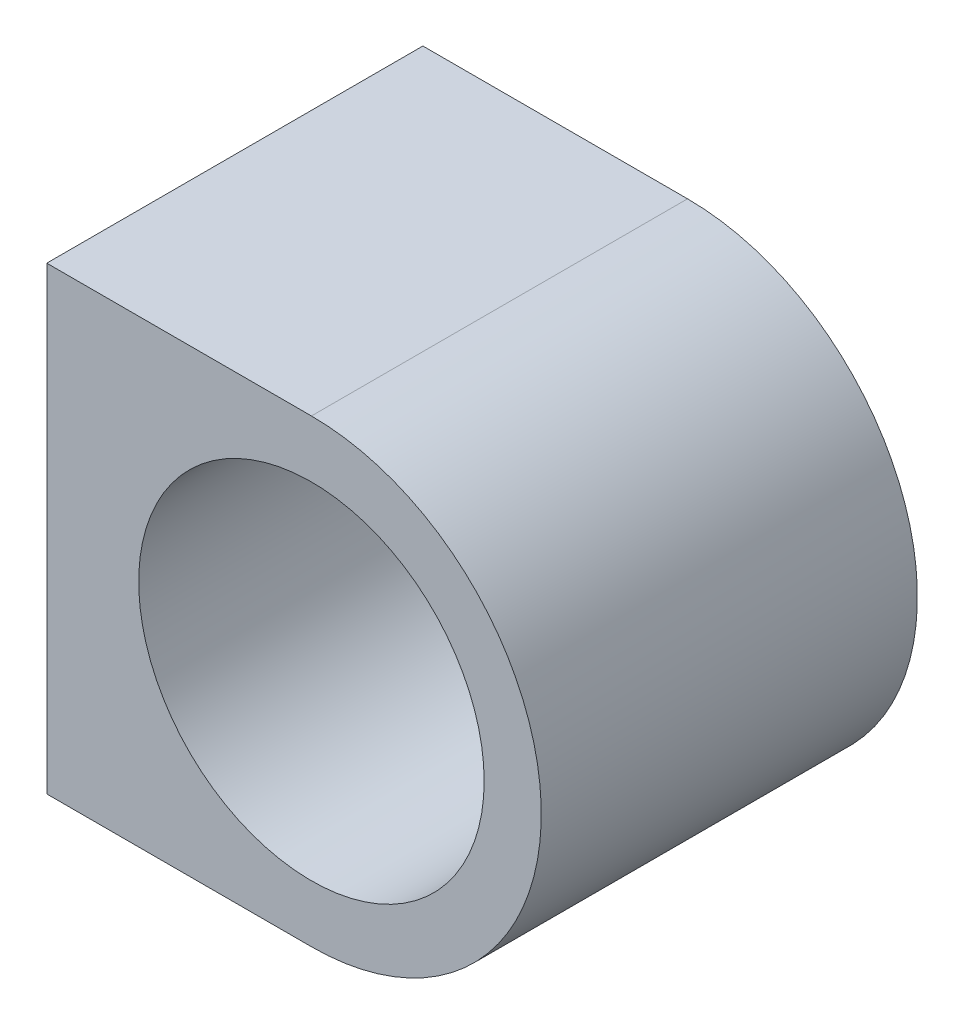
from build123d import *

# Parameters (mm, degrees)
SKETCH1_R                      = 6.2
BOSS_EXTRUDE1_DEPTH            = 13.5
F_2_7_2_7_DIAMETER_HOLE1_D     = 2.7
F_2_7_2_7_DIAMETER_HOLE1_DEPTH = 4
F_2_7_2_7_DIAMETER_HOLE1_TIP   = 0.811161836


with BuildPart() as part:
    # Sketch1 → Boss-Extrude1 (new body)
    with BuildSketch(Plane.XY):
        with BuildLine():
            Line((-9.5, 8.25), (-9.5, -8.25))
            Line((-9.5, -8.25), (0, -8.25))
            ThreePointArc((0, -8.25), (8.25, 0), (0, 8.25))
            Line((0, 8.25), (-9.5, 8.25))
        make_face()
        Circle(SKETCH1_R, mode=Mode.SUBTRACT)
    extrude(amount=BOSS_EXTRUDE1_DEPTH)

    # Ø2.7 (2.7) Diameter Hole1
    with Locations(Plane.ZY.offset(9.5)):
        with Locations((2.5, -5), (2.5, 5), (11, 5), (11, -5)):
            Hole(F_2_7_2_7_DIAMETER_HOLE1_D / 2, depth=F_2_7_2_7_DIAMETER_HOLE1_DEPTH)
            with Locations((0, 0, -(F_2_7_2_7_DIAMETER_HOLE1_DEPTH + F_2_7_2_7_DIAMETER_HOLE1_TIP / 2))):  # 118° drill point
                Cone(0, F_2_7_2_7_DIAMETER_HOLE1_D / 2, F_2_7_2_7_DIAMETER_HOLE1_TIP, mode=Mode.SUBTRACT)


solid = part.part
